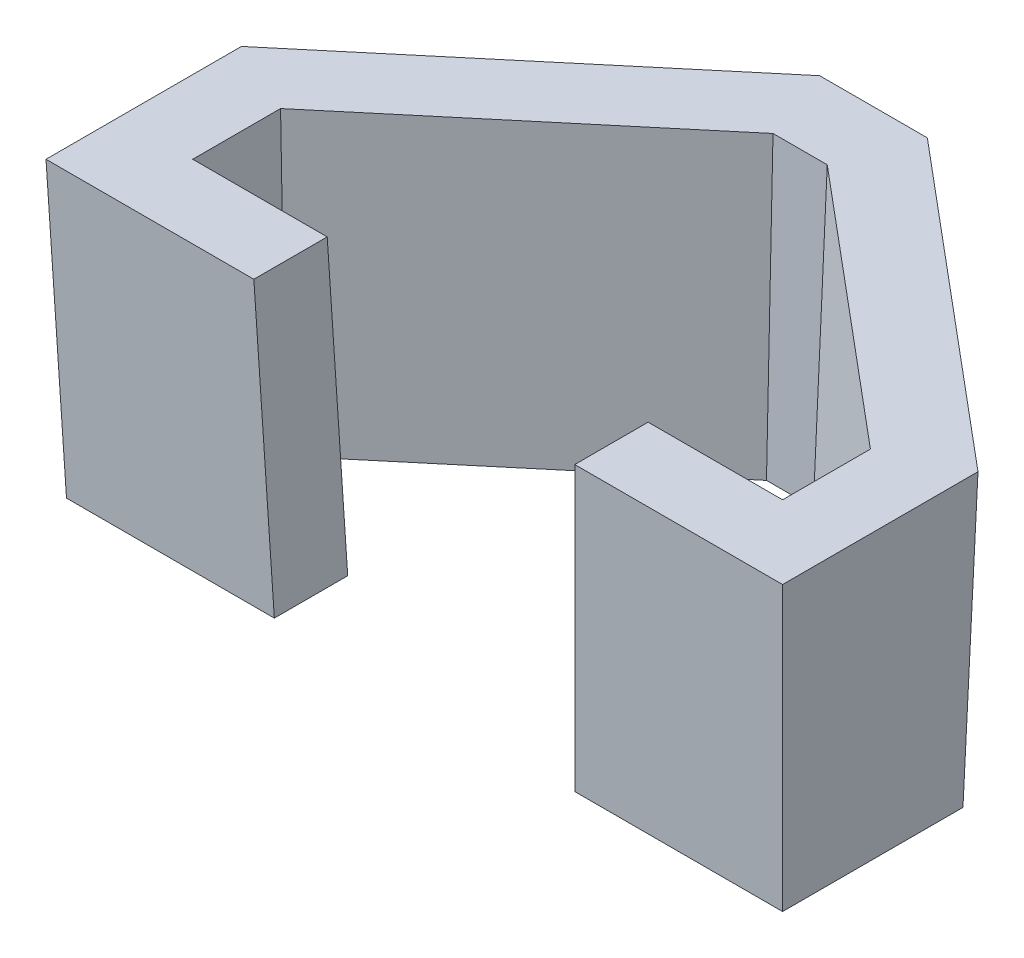
from build123d import *

# Parameters (mm, degrees)
SALIENTE_EXTRUIR1_DEPTH = 8
SALIENTE_EXTRUIR1_TAPER = -2
SALIENTE_EXTRUIR3_DEPTH = 75
SALIENTE_EXTRUIR3_TAPER = -2
CORTAR_EXTRUIR3_DEPTH   = 76.0000001
CORTAR_EXTRUIR3_TAPER   = -2
CROQUIS14_W             = 52
CROQUIS14_H             = 12.7
CORTAR_EXTRUIR4_DEPTH   = 76.0000001
CORTAR_EXTRUIR4_TAPER   = -2
CORTAR_EXTRUIR5_DEPTH   = 24.2
CORTAR_EXTRUIR5_TAPER   = -2


with BuildPart() as part:
    # Croquis1 → Saliente-Extruir1 (new body)
    with BuildSketch(Plane(origin=(0, 0, 0), x_dir=(1, 0, 0), z_dir=(0, 1, 0))):
        Polygon((0, 0), (98.55, 0), (98.55, 12.6), (53.325, 50.537320346), (45.225, 50.537320346), (0, 12.6), align=None)
    extrude(amount=SALIENTE_EXTRUIR1_DEPTH, taper=SALIENTE_EXTRUIR1_TAPER)

    # Croquis10 → Saliente-Extruir3 (add)
    with BuildSketch(Plane.XZ):
        Polygon((-12.7, 12.7), (-12.7, -18.52320689), (40.60360085, -63.237320346), (57.94639915, -63.237320346), (111.25, -18.52320689), (111.25, 12.7), align=None)
    extrude(amount=-SALIENTE_EXTRUIR3_DEPTH, taper=SALIENTE_EXTRUIR3_TAPER)

    # Croquis11 → Cortar-Extruir3 (cut, through all)
    with BuildSketch(Plane.XZ):
        Polygon((98.55, 0), (0, 0), (0, -12.6), (45.225, -50.537320346), (53.325, -50.537320346), (98.55, -12.6), align=None)
    extrude(amount=-CORTAR_EXTRUIR3_DEPTH, taper=CORTAR_EXTRUIR3_TAPER, mode=Mode.SUBTRACT)

    # Croquis14 → Cortar-Extruir4 (cut, through all)
    with BuildSketch(Plane.XZ):
        with Locations((49.275, 6.35)):
            Rectangle(CROQUIS14_W, CROQUIS14_H)
    extrude(amount=-CORTAR_EXTRUIR4_DEPTH, taper=CORTAR_EXTRUIR4_TAPER, mode=Mode.SUBTRACT)

    # Croquis16 → Cortar-Extruir5 (cut)
    with BuildSketch(Plane(origin=(0, 75, 0), x_dir=(1, 0, 0), z_dir=(0, 1, 0))):
        Polygon((101.169057712, -2.619057712), (77.894057712, -2.619057712), (77.894057712, -15.319057712), (113.869057712, -15.319057712), (113.869057712, 19.74472033), (58.899447267, 65.856378057), (39.650552733, 65.856378057), (-15.319057712, 19.74472033), (-15.319057712, -15.319057712), (20.655942288, -15.319057712), (20.655942288, -2.619057712), (-2.619057712, -2.619057712), (-2.619057712, 13.82151344), (44.271951883, 53.156378057), (54.278048117, 53.156378057), (101.169057712, 13.82151344), align=None)
    extrude(amount=-CORTAR_EXTRUIR5_DEPTH, taper=CORTAR_EXTRUIR5_TAPER, mode=Mode.SUBTRACT)


solid = part.part
